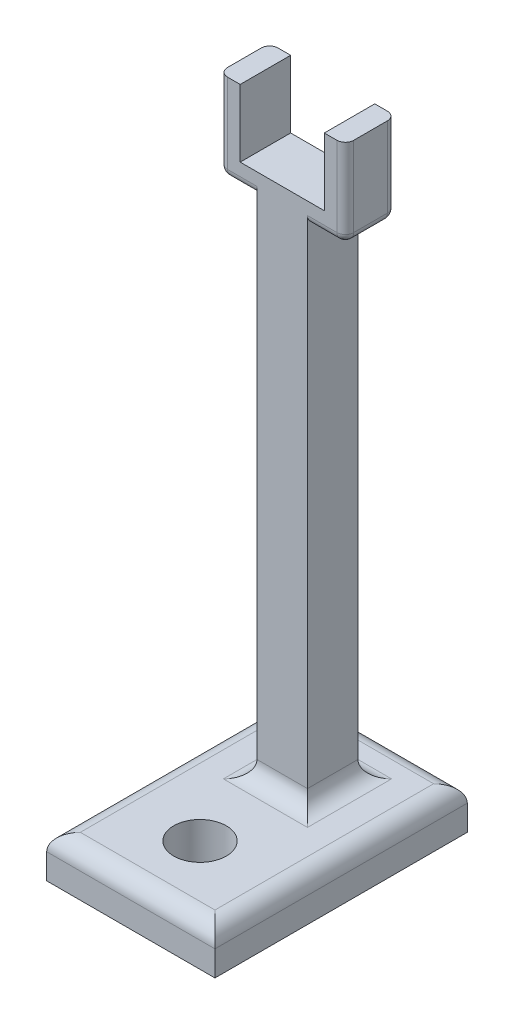
from build123d import *

# Parameters (mm, degrees)
SKETCH2_W           = 25.4
SKETCH2_H           = 38.1
BOSS_EXTRUDE1_DEPTH = 6.35
SKETCH3_W           = 7.62
SKETCH3_H           = 7.62
BOSS_EXTRUDE2_DEPTH = 76.2
BOSS_EXTRUDE3_DEPTH = 7.62
FILLET1_R           = 2.54
SKETCH6_R           = 3.96875
CUT_EXTRUDE1_DEPTH  = 12.7
FILLET2_R           = 1.27


with BuildPart() as part:
    # Sketch2 → Boss-Extrude1 (new body)
    with BuildSketch(Plane(origin=(0, 0, 0), x_dir=(1, 0, 0), z_dir=(0, 1, 0))):
        with Locations((12.7, 19.05)):
            Rectangle(SKETCH2_W, SKETCH2_H)
    extrude(amount=BOSS_EXTRUDE1_DEPTH)

    # Sketch3 → Boss-Extrude2 (add)
    with BuildSketch(Plane(origin=(0, 6.35, 0), x_dir=(1, 0, 0), z_dir=(0, 1, 0))):
        with Locations((12.7, 26.67)):
            Rectangle(SKETCH3_W, SKETCH3_H)
    extrude(amount=BOSS_EXTRUDE2_DEPTH)

    # Sketch5 → Boss-Extrude3 (add)
    with BuildSketch(Plane.XY.offset(-22.86)):
        Polygon((3.175, 82.55), (22.225, 82.55), (22.225, 95.885), (19.05, 95.885), (19.05, 85.725), (6.35, 85.725), (6.35, 95.885), (3.175, 95.885), align=None)
    extrude(amount=-BOSS_EXTRUDE3_DEPTH)

    # Fillet1
    fillet1_edges = [part.edges().sort_by_distance(p)[0] for p in [
        (25.4, 6.35, -19.05),
        (8.89, 6.35, -26.67),
        (12.7, 6.35, -22.86),
        (12.7, 6.35, -38.1),
        (16.51, 6.35, -26.67),
        (12.7, 6.35, -30.48),
        (0, 6.35, -19.05),
        (12.7, 6.35, 0),
    ]]
    fillet(fillet1_edges, radius=FILLET1_R)

    # Sketch6 → Cut-Extrude1 (cut)
    with BuildSketch(Plane(origin=(0, 6.35, 0), x_dir=(1, 0, 0), z_dir=(0, 1, 0))):
        with Locations((12.7, 10.446236213)):
            Circle(SKETCH6_R)
    extrude(amount=-CUT_EXTRUDE1_DEPTH, mode=Mode.SUBTRACT)

    # Fillet2
    fillet2_edges = [part.edges().sort_by_distance(p)[0] for p in [
        (6.0325, 82.55, -30.48),
        (3.175, 89.2175, -30.48),
        (3.175, 82.55, -26.67),
        (22.225, 89.2175, -30.48),
        (19.3675, 82.55, -30.48),
        (22.225, 82.55, -26.67),
        (3.175, 89.2175, -22.86),
        (6.0325, 82.55, -22.86),
        (19.3675, 82.55, -22.86),
        (22.225, 89.2175, -22.86),
    ]]
    fillet(fillet2_edges, radius=FILLET2_R)


solid = part.part
